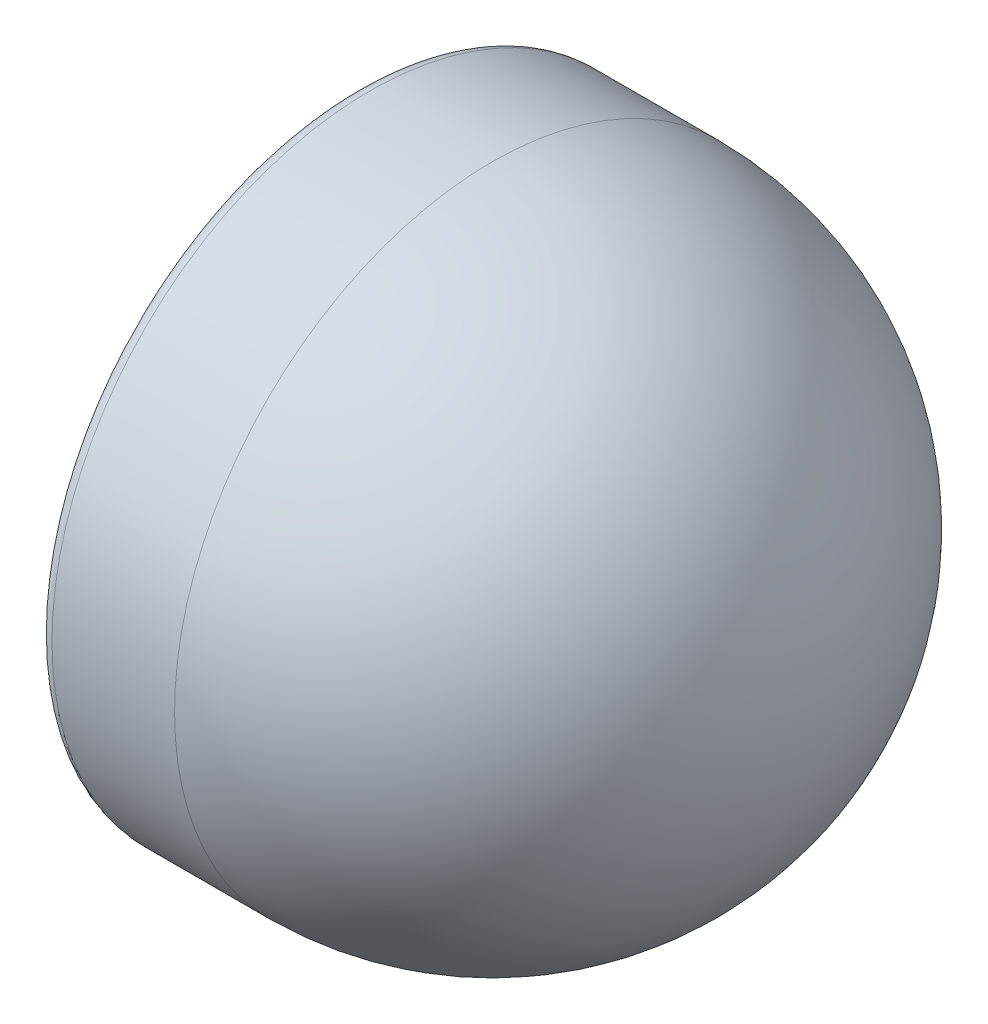
from build123d import *


with BuildPart() as part:
    # Sketch1 → Revolve1 (revolve)
    with BuildSketch(Plane.XY):
        with BuildLine():
            Line((-70, 70), (-97, 70))
            ThreePointArc((-97, 70), (-99.121320344, 69.121320344), (-100, 67))
            Line((-100, 67), (-100, 61.5))
            ThreePointArc((-100, 61.5), (-99.560660172, 60.439339828), (-98.5, 60))
            Line((-98.5, 60), (-96.621320344, 60))
            ThreePointArc((-96.621320344, 60), (-96.047295195, 60.114180701), (-95.560660172, 60.439339828))
            Line((-95.560660172, 60.439339828), (-92.000906073, 63.999093927))
            Line((-92.000906073, 63.999093927), (-92.000906073, 64.706200709))
            Line((-92.000906073, 64.706200709), (-92.708012854, 64.706200709))
            Line((-92.708012854, 64.706200709), (-96.267766953, 61.146446609))
            ThreePointArc((-96.267766953, 61.146446609), (-96.429978627, 61.038060234), (-96.621320344, 61))
            Line((-96.621320344, 61), (-98.5, 61))
            ThreePointArc((-98.5, 61), (-98.853553391, 61.146446609), (-99, 61.5))
            Line((-99, 61.5), (-99, 67))
            ThreePointArc((-99, 67), (-98.414213562, 68.414213562), (-97, 69))
            Line((-97, 69), (-70, 69))
            ThreePointArc((-70, 69), (-21.209632098, 48.790367902), (-1, 0))
            Line((-1, 0), (0, 0))
            ThreePointArc((0, 0), (-20.502525317, 49.497474683), (-70, 70))
        make_face()
    revolve(axis=Axis((-1, 0, 0), (1, 0, 0)))


solid = part.part
